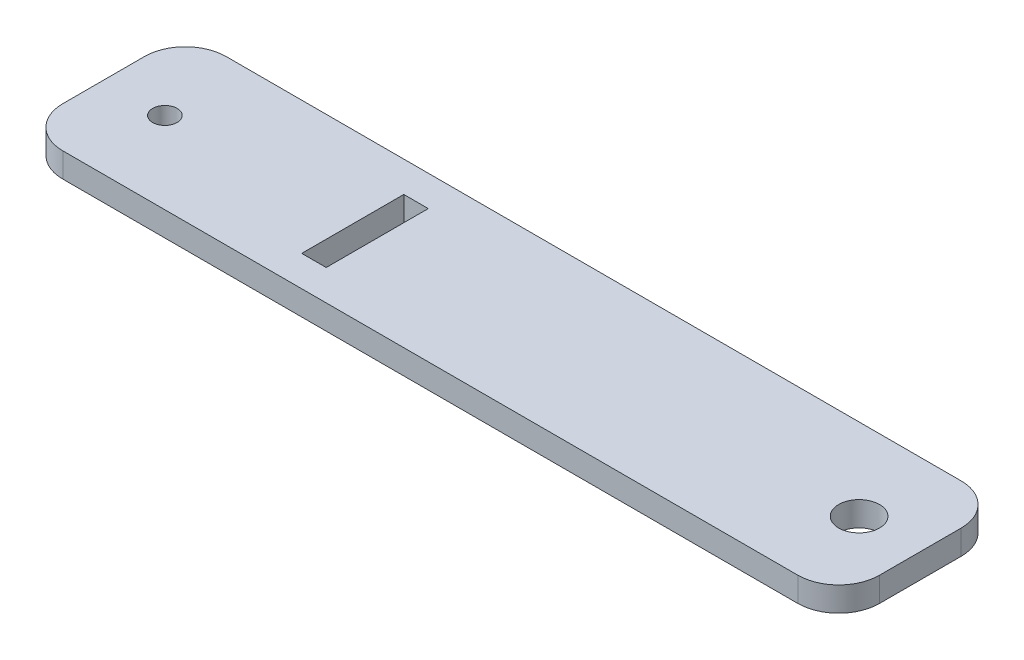
from build123d import *

# Parameters (mm, degrees)
SKETCH2_R           = 5
SKETCH2_R_2         = 3
SKETCH2_W           = 6
SKETCH2_H           = 25
BOSS_EXTRUDE1_DEPTH = 6


with BuildPart() as part:
    # Sketch2 → Boss-Extrude1 (new body)
    with BuildSketch(Plane(origin=(0, 0, 0), x_dir=(1, 0, 0), z_dir=(0, 1, 0))):
        with BuildLine():
            Line((-90, 20), (90, 20))
            ThreePointArc((90, 20), (97.071067812, 17.071067812), (100, 10))
            Line((100, 10), (100, -10))
            ThreePointArc((100, -10), (97.071067812, -17.071067812), (90, -20))
            Line((90, -20), (-90, -20))
            ThreePointArc((-90, -20), (-97.071067812, -17.071067812), (-100, -10))
            Line((-100, -10), (-100, 10))
            ThreePointArc((-100, 10), (-97.071067812, 17.071067812), (-90, 20))
        make_face()
        with Locations((85, 0)):
            Circle(SKETCH2_R, mode=Mode.SUBTRACT)
        with Locations((-85, 0)):
            Circle(SKETCH2_R_2, mode=Mode.SUBTRACT)
        with Locations((-36, 0)):
            Rectangle(SKETCH2_W, SKETCH2_H, mode=Mode.SUBTRACT)
    extrude(amount=BOSS_EXTRUDE1_DEPTH)


solid = part.part
